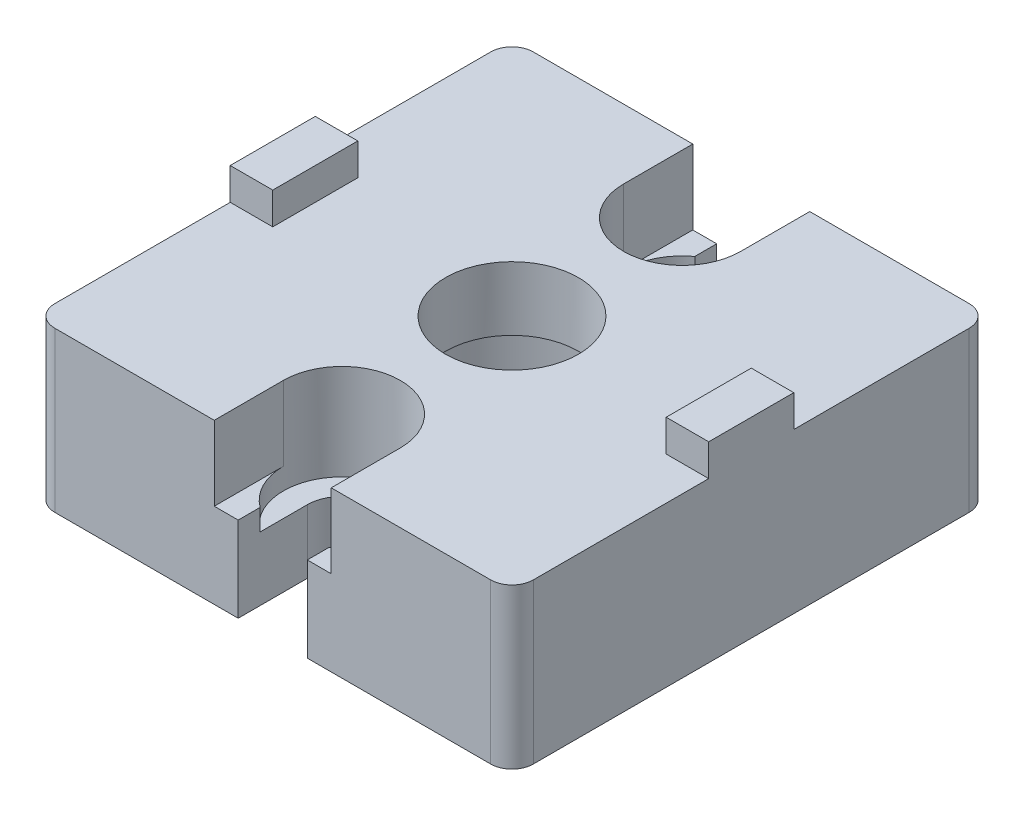
from build123d import *

# Parameters (mm, degrees)
SKETCH_1_W          = 45
SKETCH_1_H          = 45
EXTRUDE_1_DEPTH     = 15
SKETCH_2_W          = 4
SKETCH_2_H          = 8
EXTRUDE_2_DEPTH     = 3
SKETCH_3_R          = 6.25
CUT_EXTRUDE_1_DEPTH = 16
SKETCH_4_R          = 10
CUT_EXTRUDE_2_DEPTH = 9
CUT_EXTRUDE_3_DEPTH = 7
SKETCH_6_R          = 5.5
CUT_EXTRUDE_4_DEPTH = 2
FILLET_1_R          = 2


with BuildPart() as part:
    # Эскиз1 → Бобышка-Вытянуть1 (new body)
    with BuildSketch(Plane(origin=(0, 0, 0), x_dir=(1, 0, 0), z_dir=(0, 1, 0))):
        Rectangle(SKETCH_1_W, SKETCH_1_H)
    extrude(amount=EXTRUDE_1_DEPTH)

    # Эскиз2 → Бобышка-Вытянуть2 (add)
    with BuildSketch(Plane(origin=(0, 15, 0), x_dir=(1, 0, 0), z_dir=(0, 1, 0))):
        with Locations((-20.5, 0)):
            Rectangle(SKETCH_2_W, SKETCH_2_H)
        with Locations((20.5, 0)):
            Rectangle(SKETCH_2_W, SKETCH_2_H)
    extrude(amount=EXTRUDE_2_DEPTH)

    # Эскиз3 → Вырез-Вытянуть1 (cut, through all)
    with BuildSketch(Plane(origin=(0, 15, 0), x_dir=(1, 0, 0), z_dir=(0, 1, 0))):
        with Locations(Location((0, 0, 0), (0, 0, 270))):  # turned: the seam where the file's is
            Circle(SKETCH_3_R)
        with BuildLine():
            Line((-3.25, -22.5), (-3.25, -16))
            ThreePointArc((-3.25, -16), (0, -12.75), (3.25, -16))
            Line((3.25, -16), (3.25, -22.5))
            Line((3.25, -22.5), (-3.25, -22.5))
        make_face()
        with BuildLine():
            Line((3.25, 16), (3.25, 22.5))
            Line((3.25, 22.5), (-3.25, 22.5))
            Line((-3.25, 22.5), (-3.25, 16))
            ThreePointArc((-3.25, 16), (0, 12.75), (3.25, 16))
        make_face()
    extrude(amount=-CUT_EXTRUDE_1_DEPTH, mode=Mode.SUBTRACT)

    # Эскиз4 → Вырез-Вытянуть2 (cut)
    with BuildSketch(Plane.XZ):
        with Locations(Location((0, 0, 0), (0, 0, 270))):  # turned: the seam where the file's is
            Circle(SKETCH_4_R)
    extrude(amount=-CUT_EXTRUDE_2_DEPTH, mode=Mode.SUBTRACT)

    # Эскиз5 → Вырез-Вытянуть3 (cut)
    with BuildSketch(Plane(origin=(0, 15, 0), x_dir=(1, 0, 0), z_dir=(0, 1, 0))):
        with BuildLine():
            Line((-5.5, -22.5), (-5.5, -16))
            ThreePointArc((-5.5, -16), (0, -10.5), (5.5, -16))
            Line((5.5, -16), (5.5, -22.5))
            Line((5.5, -22.5), (-5.5, -22.5))
        make_face()
        with BuildLine():
            Line((5.5, 16), (5.5, 22.5))
            Line((5.5, 22.5), (-5.5, 22.5))
            Line((-5.5, 22.5), (-5.5, 16))
            ThreePointArc((-5.5, 16), (0, 10.5), (5.5, 16))
        make_face()
    extrude(amount=-CUT_EXTRUDE_3_DEPTH, mode=Mode.SUBTRACT)

    # Эскиз6 → Вырез-Вытянуть4 (cut)
    with BuildSketch(Plane(origin=(0, 8, 0), x_dir=(1, 0, 0), z_dir=(0, 1, 0))):
        with Locations((0, -16)):
            Circle(SKETCH_6_R)
        with Locations((0, 16)):
            Circle(SKETCH_6_R)
    extrude(amount=-CUT_EXTRUDE_4_DEPTH, mode=Mode.SUBTRACT)

    # Скругление1
    fillet_1_edges = [part.edges().sort_by_distance(p)[0] for p in [
        (-22.5, 7.5, -22.5),
        (22.5, 7.5, -22.5),
        (22.5, 7.5, 22.5),
        (-22.5, 7.5, 22.5),
    ]]
    fillet(fillet_1_edges, radius=FILLET_1_R)


solid = part.part
